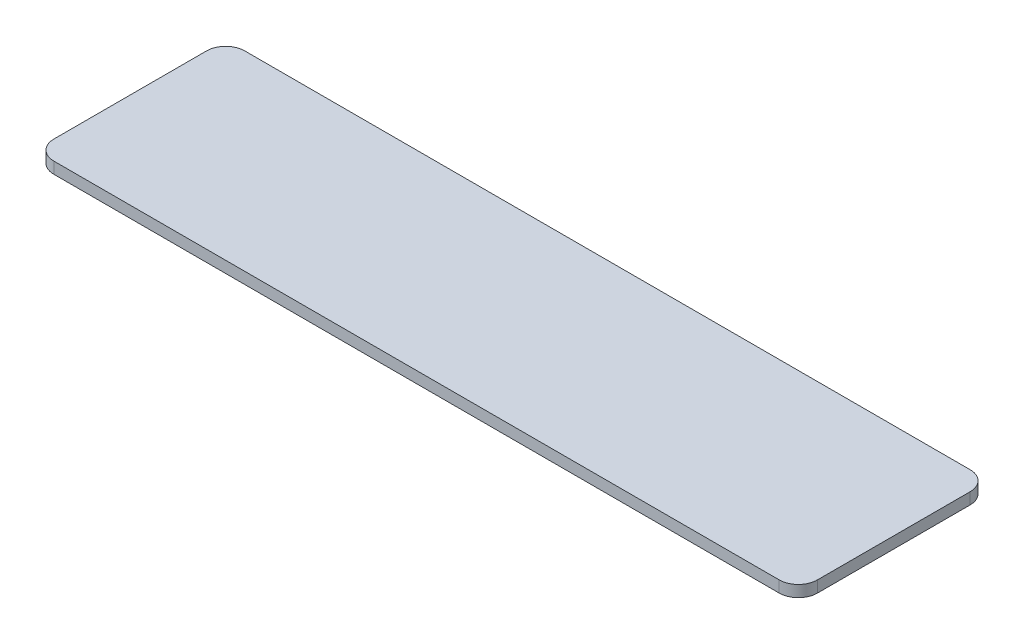
from build123d import *

# Parameters (mm, degrees)
SKETCH1_W           = 200
SKETCH1_H           = 50
BOSS_EXTRUDE1_DEPTH = 3
FILLET1_R           = 5


with BuildPart() as part:
    # Sketch1 → Boss-Extrude1 (new body)
    with BuildSketch(Plane(origin=(0, 0, 0), x_dir=(1, 0, 0), z_dir=(0, 1, 0))):
        Rectangle(SKETCH1_W, SKETCH1_H)
    extrude(amount=BOSS_EXTRUDE1_DEPTH)

    # Fillet1
    fillet1_edges = [part.edges().sort_by_distance(p)[0] for p in [
        (100, 1.5, 25),
        (-100, 1.5, 25),
        (-100, 1.5, -25),
        (100, 1.5, -25),
    ]]
    fillet(fillet1_edges, radius=FILLET1_R)


solid = part.part
